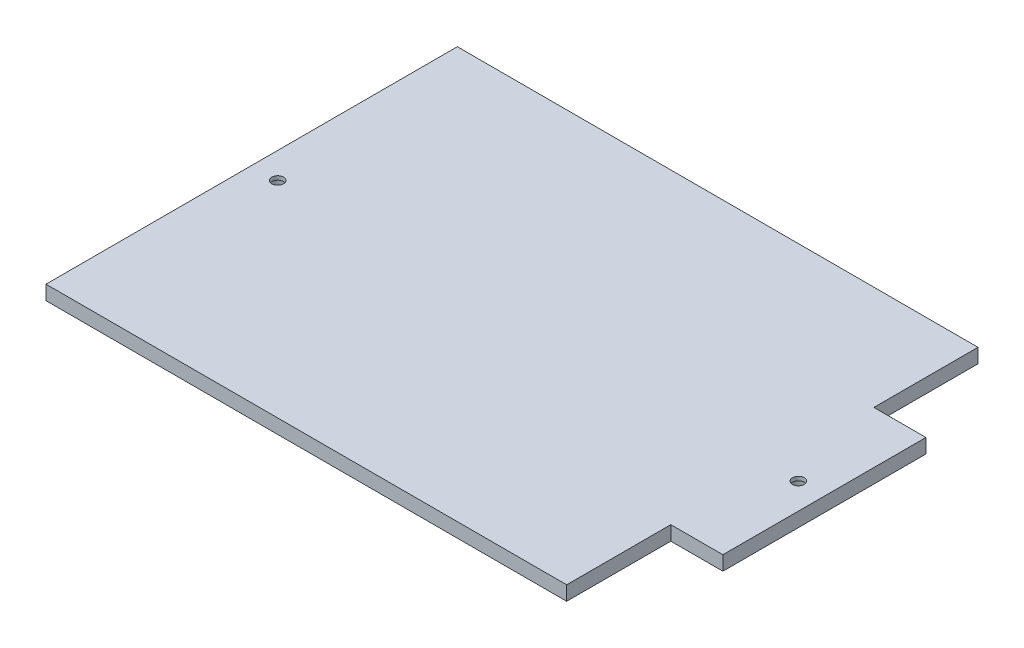
from build123d import *

# Parameters (mm, degrees)
SKETCH1_W                      = 220
SKETCH1_H                      = 158
BOSS_EXTRUDE1_DEPTH            = 5.5
CBORE_FOR_M4_SHCS1_D           = 4.5
CBORE_FOR_M4_SHCS1_CBORE_D     = 8
CBORE_FOR_M4_SHCS1_CBORE_DEPTH = 4
SKETCH6_W                      = 20
SKETCH6_H                      = 40
CUT_EXTRUDE2_DEPTH             = 6.5


with BuildPart() as part:
    # Sketch1 → Boss-Extrude1 (new body)
    with BuildSketch(Plane(origin=(0, 0, 0), x_dir=(1, 0, 0), z_dir=(0, 1, 0))):
        Rectangle(SKETCH1_W, SKETCH1_H)
    extrude(amount=BOSS_EXTRUDE1_DEPTH)

    # CBORE for M4 SHCS1 (through all)
    with Locations(Plane.XZ):
        with Locations((100, 0)):
            cbore_for_m4_shcs1 = CounterBoreHole(CBORE_FOR_M4_SHCS1_D / 2, CBORE_FOR_M4_SHCS1_CBORE_D / 2, CBORE_FOR_M4_SHCS1_CBORE_DEPTH)

    # Mirror2: CBORE for M4 SHCS1 across plane
    add(cbore_for_m4_shcs1.mirror(Plane(origin=(0, 0, 0), x_dir=(0, 0, 1), z_dir=(1, 0, 0))), mode=Mode.SUBTRACT)

    # Sketch6 → Cut-Extrude2 (cut, through all)
    with BuildSketch(Plane(origin=(0, 5.5, 0), x_dir=(1, 0, 0), z_dir=(0, 1, 0))):
        with Locations((100, 59)):
            Rectangle(SKETCH6_W, SKETCH6_H)
    cut_extrude2 = extrude(amount=-CUT_EXTRUDE2_DEPTH, mode=Mode.SUBTRACT)

    # Mirror3: Cut-Extrude2 across plane
    add(cut_extrude2.mirror(Plane.XY), mode=Mode.SUBTRACT)


solid = part.part
